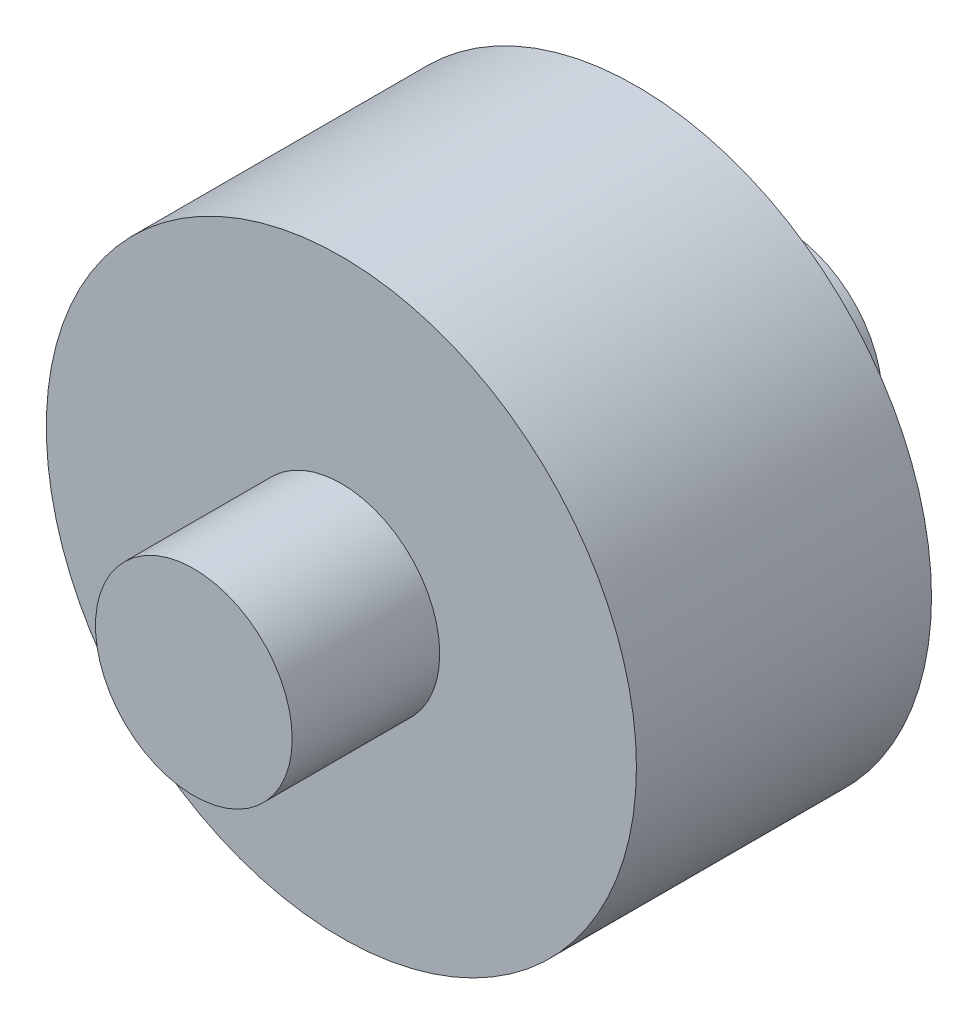
from build123d import *

# Parameters (mm, degrees)
SKETCH2_R           = 9.525
BOSS_EXTRUDE2_DEPTH = 4.7625
SKETCH5_R           = 3.175
BOSS_EXTRUDE3_DEPTH = 9.525
SKETCH6_R           = 3.175
CUT_EXTRUDE3_DEPTH  = 10.525


with BuildPart() as part:
    # Sketch2 → Boss-Extrude2 (new body, symmetric)
    with BuildSketch(Plane.XY):
        Circle(SKETCH2_R)
    extrude(amount=BOSS_EXTRUDE2_DEPTH, both=True)

    # Sketch5 → Boss-Extrude3 (add, symmetric)
    with BuildSketch(Plane.XY):
        Circle(SKETCH5_R)
    extrude(amount=BOSS_EXTRUDE3_DEPTH, both=True)

    # Sketch6 → Cut-Extrude3 (cut, through all)
    with BuildSketch(Plane(origin=(0, 0, 0), x_dir=(0, 0, -1), z_dir=(1, 0, 0))):
        Circle(SKETCH6_R)
    extrude(amount=-CUT_EXTRUDE3_DEPTH, mode=Mode.SUBTRACT)


solid = part.part
